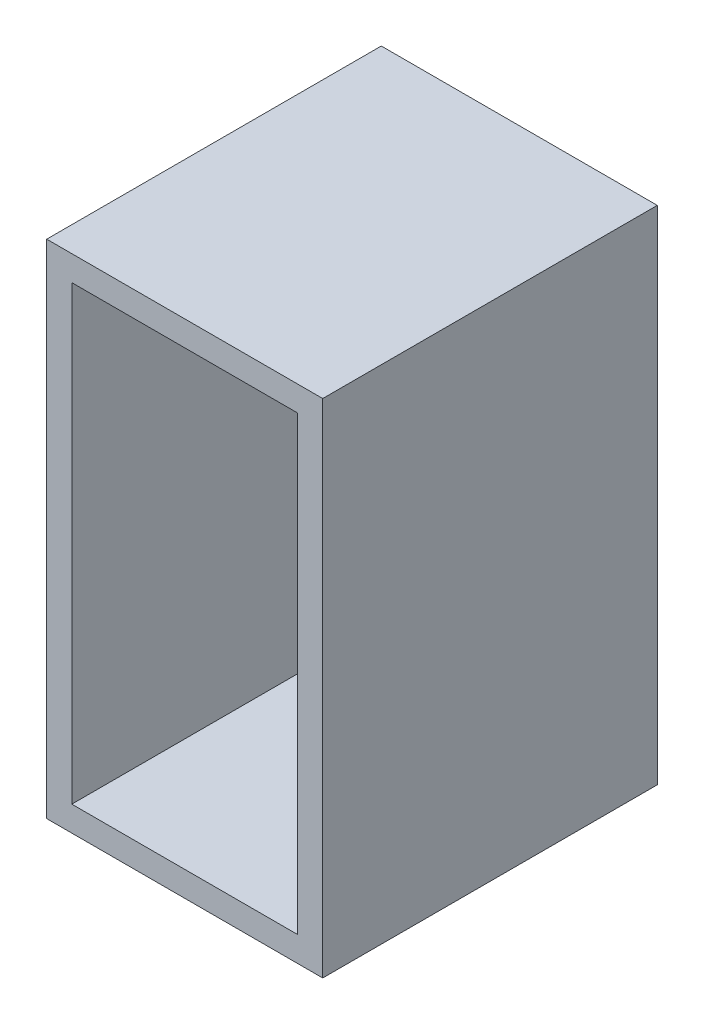
from build123d import *

# Parameters (mm, degrees)
SKETCH_1_W      = 13.5
SKETCH_1_H      = 27
SKETCH_1_W_2    = 10.5
SKETCH_1_H_2    = 5.5
EXTRUDE_1_DEPTH = 1.5
SKETCH_1_3_W    = 16.5
SKETCH_1_3_H    = 30
SKETCH_1_3_W_2  = 13.5
SKETCH_1_3_H_2  = 27
EXTRUDE_2_DEPTH = 20


with BuildPart() as part:
    # 스케치1 → 보스-돌출1 (new body)
    with BuildSketch(Plane.XY):
        with Locations((8.25, -15)):
            Rectangle(SKETCH_1_W, SKETCH_1_H)
        with Locations((8.25, -5.75)):
            Rectangle(SKETCH_1_W_2, SKETCH_1_H_2, mode=Mode.SUBTRACT)
    extrude(amount=EXTRUDE_1_DEPTH)

    # 스케치1<3> → 보스-돌출2 (add)
    with BuildSketch(Plane.XY):
        with Locations((8.25, -15)):
            Rectangle(SKETCH_1_3_W, SKETCH_1_3_H)
        with Locations((8.25, -15)):
            Rectangle(SKETCH_1_3_W_2, SKETCH_1_3_H_2, mode=Mode.SUBTRACT)
    extrude(amount=EXTRUDE_2_DEPTH)


solid = part.part
